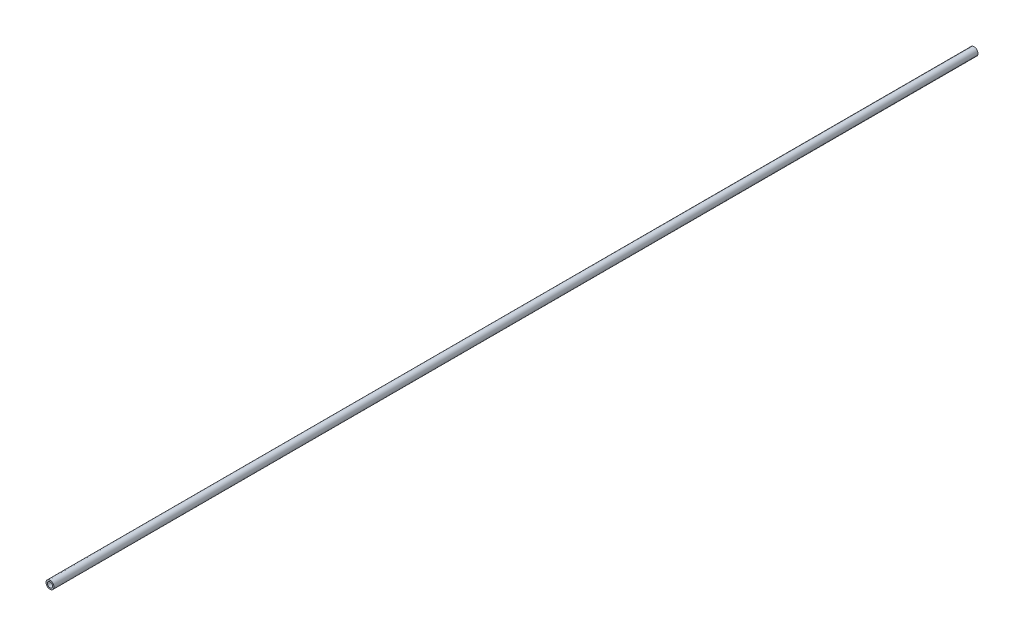
from build123d import *

# Parameters (mm, degrees)
SKETCH1_R              = 1.5
SKETCH1_R_2            = 1
TAIL_ROD_EXTRUDE_DEPTH = 350


with BuildPart() as part:
    # Sketch1 → tail_rod_extrude (new body)
    with BuildSketch(Plane.XY):
        Circle(SKETCH1_R)
        Circle(SKETCH1_R_2, mode=Mode.SUBTRACT)
    extrude(amount=TAIL_ROD_EXTRUDE_DEPTH)


solid = part.part
